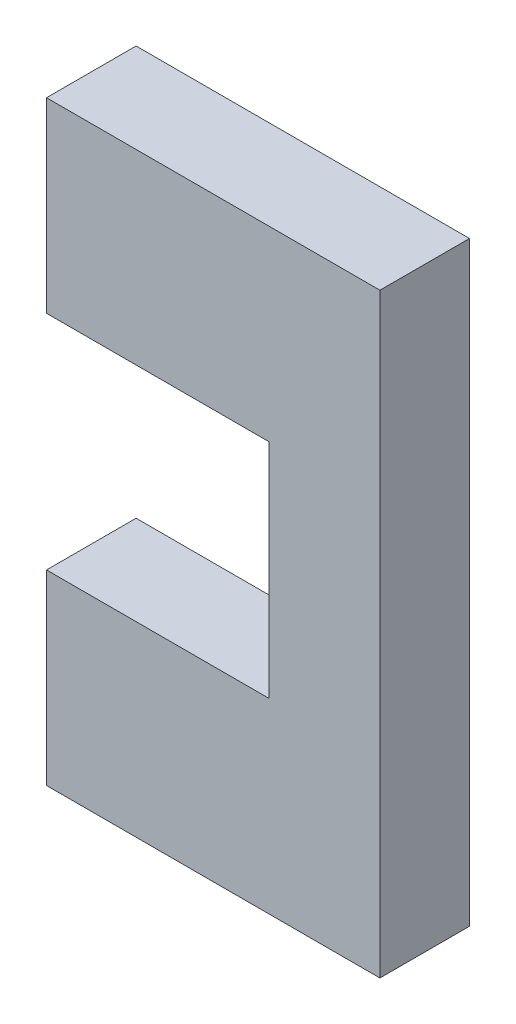
from build123d import *

# Parameters (mm, degrees)
BOSS_EXTRUDE2_DEPTH = 10.237155


with BuildPart() as part:
    # Sketch1 → Boss-Extrude2 (new body)
    with BuildSketch(Plane.XY):
        Polygon((38.1, 215.218), (38.1, 193.882), (63.5, 193.882), (63.5, 168.482), (38.1, 168.482), (38.1, 147.146), (76.2, 147.146), (76.2, 215.218), align=None)
    extrude(amount=BOSS_EXTRUDE2_DEPTH)


solid = part.part
